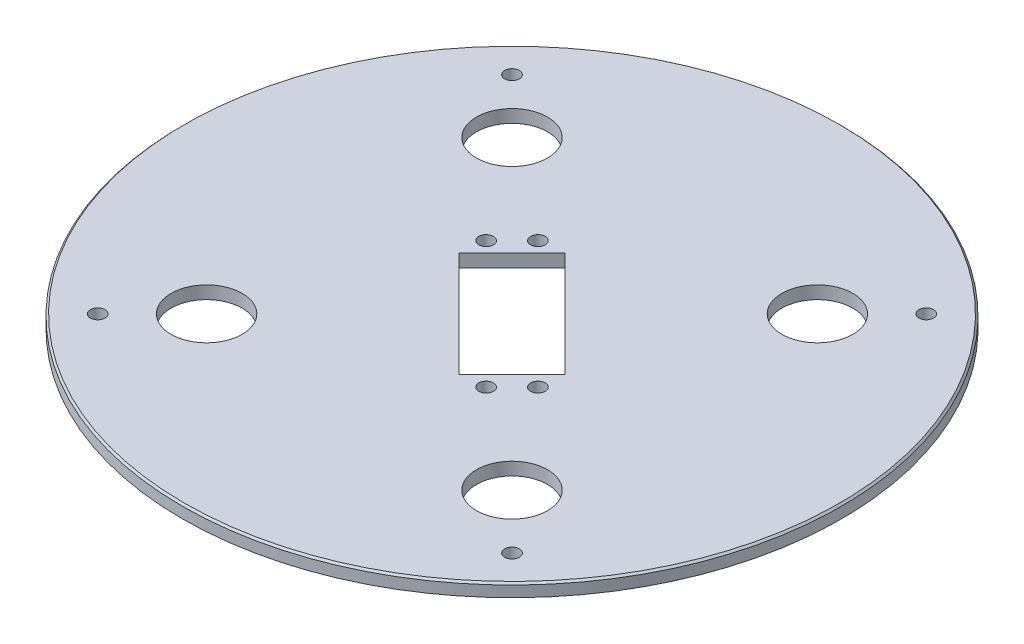
from build123d import *

# Parameters (mm, degrees)
SKETCH1_R           = 90
SKETCH1_R_2         = 9.7
SKETCH1_R_3         = 2
BOSS_EXTRUDE1_DEPTH = 3.5
CHAMFER1_SIZE       = 0.5


with BuildPart() as part:
    # Sketch1 → Boss-Extrude1 (new body)
    with BuildSketch(Plane(origin=(0, 0, 0), x_dir=(1, 0, 0), z_dir=(0, 1, 0))):
        Circle(SKETCH1_R)
        with Locations((-41.7, 41.7)):
            Circle(SKETCH1_R_2, mode=Mode.SUBTRACT)
        with Locations((41.7, 41.7)):
            Circle(SKETCH1_R_2, mode=Mode.SUBTRACT)
        with Locations((41.7, -41.7)):
            Circle(SKETCH1_R_2, mode=Mode.SUBTRACT)
        with Locations((-41.7, -41.7)):
            Circle(SKETCH1_R_2, mode=Mode.SUBTRACT)
        with Locations((-56.568542495, 56.568542495)):
            Circle(SKETCH1_R_3, mode=Mode.SUBTRACT)
        with Locations((-56.568542495, -56.568542495)):
            Circle(SKETCH1_R_3, mode=Mode.SUBTRACT)
        with Locations((56.568542495, 56.568542495)):
            Circle(SKETCH1_R_3, mode=Mode.SUBTRACT)
        with Locations((56.568542495, -56.568542495)):
            Circle(SKETCH1_R_3, mode=Mode.SUBTRACT)
        with Locations((-13.788582233, 20.859650045)):
            Circle(SKETCH1_R_3, mode=Mode.SUBTRACT)
        with Locations((20.859650045, -13.788582233)):
            Circle(SKETCH1_R_3, mode=Mode.SUBTRACT)
        with Locations((13.788582233, -20.859650045)):
            Circle(SKETCH1_R_3, mode=Mode.SUBTRACT)
        with Locations((-20.859650045, 13.788582233)):
            Circle(SKETCH1_R_3, mode=Mode.SUBTRACT)
        Polygon((7.14177849, -21.637467504), (-21.637467504, 7.14177849), (-7.14177849, 21.637467504), (21.637467504, -7.14177849), align=None, mode=Mode.SUBTRACT)
    extrude(amount=BOSS_EXTRUDE1_DEPTH)

    # Chamfer1
    chamfer1_edges = [part.edges().sort_by_distance(p)[0] for p in [
        (-90, 3.5, 0),
    ]]
    chamfer(chamfer1_edges, length=CHAMFER1_SIZE)


solid = part.part
